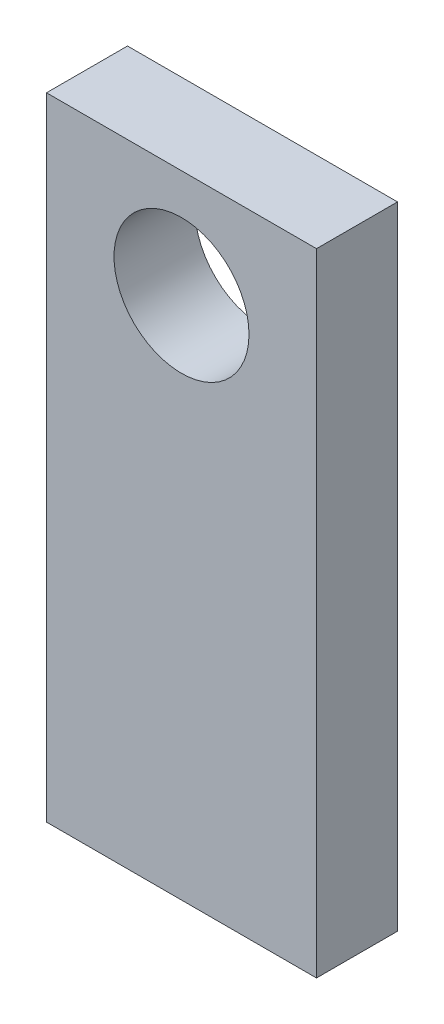
from build123d import *

# Parameters (mm, degrees)
CROQUIS1_W              = 63.5
CROQUIS1_H              = 148.55
SALIENTE_EXTRUIR1_DEPTH = 19.05
CROQUIS2_R              = 15.875
CORTAR_EXTRUIR1_DEPTH   = 19.05


with BuildPart() as part:
    # Croquis1 → Saliente-Extruir1 (new body)
    with BuildSketch(Plane.XY):
        with Locations((31.75, 74.275)):
            Rectangle(CROQUIS1_W, CROQUIS1_H)
    extrude(amount=SALIENTE_EXTRUIR1_DEPTH)

    # Croquis2 → Cortar-Extruir1 (cut)
    with BuildSketch(Plane.XY.offset(19.05)):
        with Locations((31.75, 123.15)):
            Circle(CROQUIS2_R)
    extrude(amount=-CORTAR_EXTRUIR1_DEPTH, mode=Mode.SUBTRACT)


solid = part.part
